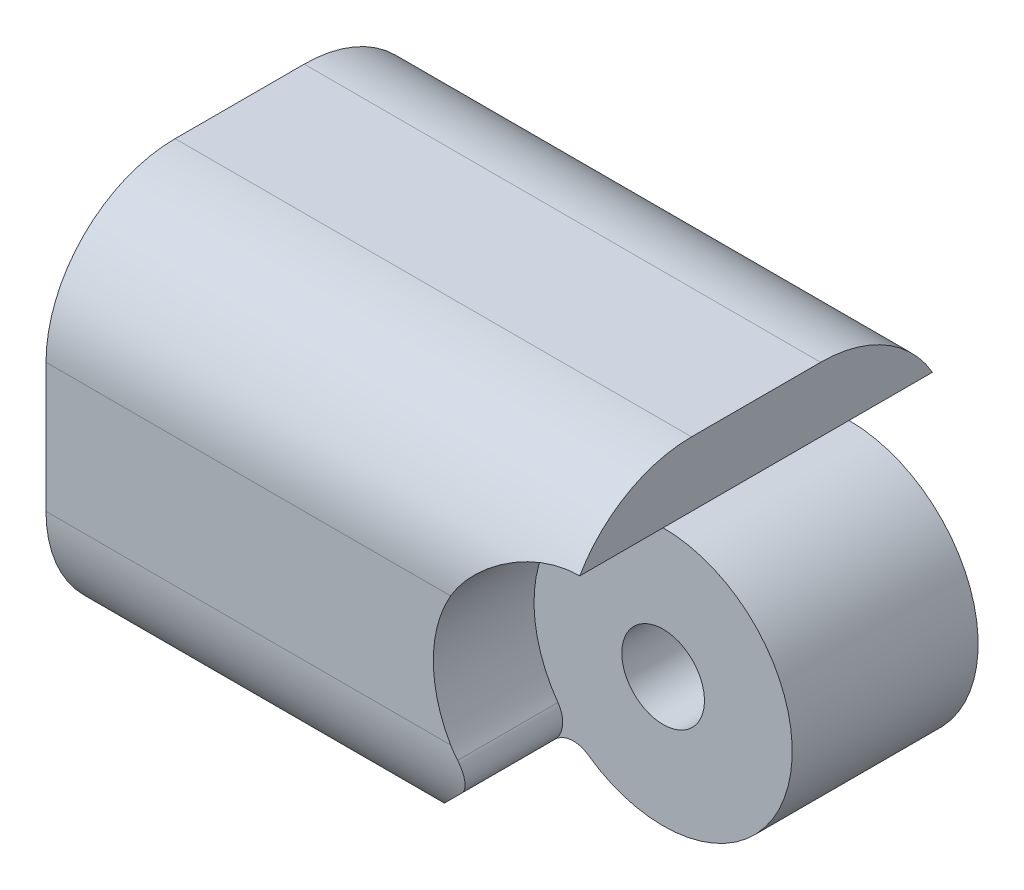
from build123d import *

# Parameters (mm, degrees)
SKETCH1_R           = 1.6
BOSS_EXTRUDE1_DEPTH = 7.5
SKETCH2_R           = 5.075
SKETCH2_R_2         = 1.6
CUT_EXTRUDE1_DEPTH  = 3.75
FILLET1_R           = 5
SKETCH3_R           = 5
CUT_EXTRUDE2_DEPTH  = 3.9
CUT_EXTRUDE5_DEPTH  = 8.5
FILLET2_R           = 1
FILLET3_R           = 1


with BuildPart() as part:
    # Sketch1 → Boss-Extrude1 (new body)
    with BuildSketch(Plane.XY):
        with BuildLine():
            Line((10, 5), (10, 7.5))
            Line((10, 7.5), (-10, 7.5))
            Line((-10, 7.5), (-10, -7.5))
            Line((-10, -7.5), (10, -7.5))
            Line((10, -7.5), (10, -5))
            ThreePointArc((10, -5), (15, 0), (10, 5))
        make_face()
        with Locations((10, 0)):
            Circle(SKETCH1_R, mode=Mode.SUBTRACT)
    extrude(amount=BOSS_EXTRUDE1_DEPTH)

    # Sketch2 → Cut-Extrude1 (cut)
    with BuildSketch(Plane.XY.offset(7.5)):
        with Locations((-10, 0)):
            Circle(SKETCH2_R)
        with Locations((-10, 0)):
            Circle(SKETCH2_R_2, mode=Mode.SUBTRACT)
    extrude(amount=-CUT_EXTRUDE1_DEPTH, mode=Mode.SUBTRACT)

    # Fillet1
    fillet1_edges = [part.edges().sort_by_distance(p)[0] for p in [
        (0, -7.5, 0),
        (0, 7.5, 0),
    ]]
    fillet(fillet1_edges, radius=FILLET1_R)

    # Sketch3 → Cut-Extrude2 (cut)
    with BuildSketch(Plane(origin=(0, 0, 0), x_dir=(-1, 0, 0), z_dir=(0, 0, -1))):
        with Locations((-10, 0)):
            Circle(SKETCH3_R)
    extrude(amount=-CUT_EXTRUDE2_DEPTH, mode=Mode.SUBTRACT)

    # Sketch5 → Cut-Extrude5 (cut, through all)
    with BuildSketch(Plane(origin=(0, 0, 0), x_dir=(-1, 0, 0), z_dir=(0, 0, -1))):
        with BuildLine():
            Line((-6.464466094, -3.535533906), (-2.5, -7.5))
            Line((-2.5, -7.5), (-10, -7.5))
            Line((-10, -7.5), (-10, -5))
            ThreePointArc((-10, -5), (-8.086582838, -4.619397663), (-6.464466094, -3.535533906))
        make_face()
    extrude(amount=-CUT_EXTRUDE5_DEPTH, mode=Mode.SUBTRACT)

    # Fillet2
    fillet2_edges = [part.edges().sort_by_distance(p)[0] for p in [
        (6.464466094, -3.535533906, 2.00420414),
    ]]
    fillet(fillet2_edges, radius=FILLET2_R)

    # Mirror2: part across plane


with BuildPart() as part_1:
    add(part.part)
    add(part.part.mirror(Plane(origin=(10, 0, 7.5), x_dir=(1, 0, 0), z_dir=(0, 0, 1))))

    # Fillet3
    fillet3_edges = [part_1.edges().sort_by_distance(p)[0] for p in [
        (6.464466094, -3.535533906, 7.5),
    ]]
    fillet(fillet3_edges, radius=FILLET3_R)


solid = part_1.part
